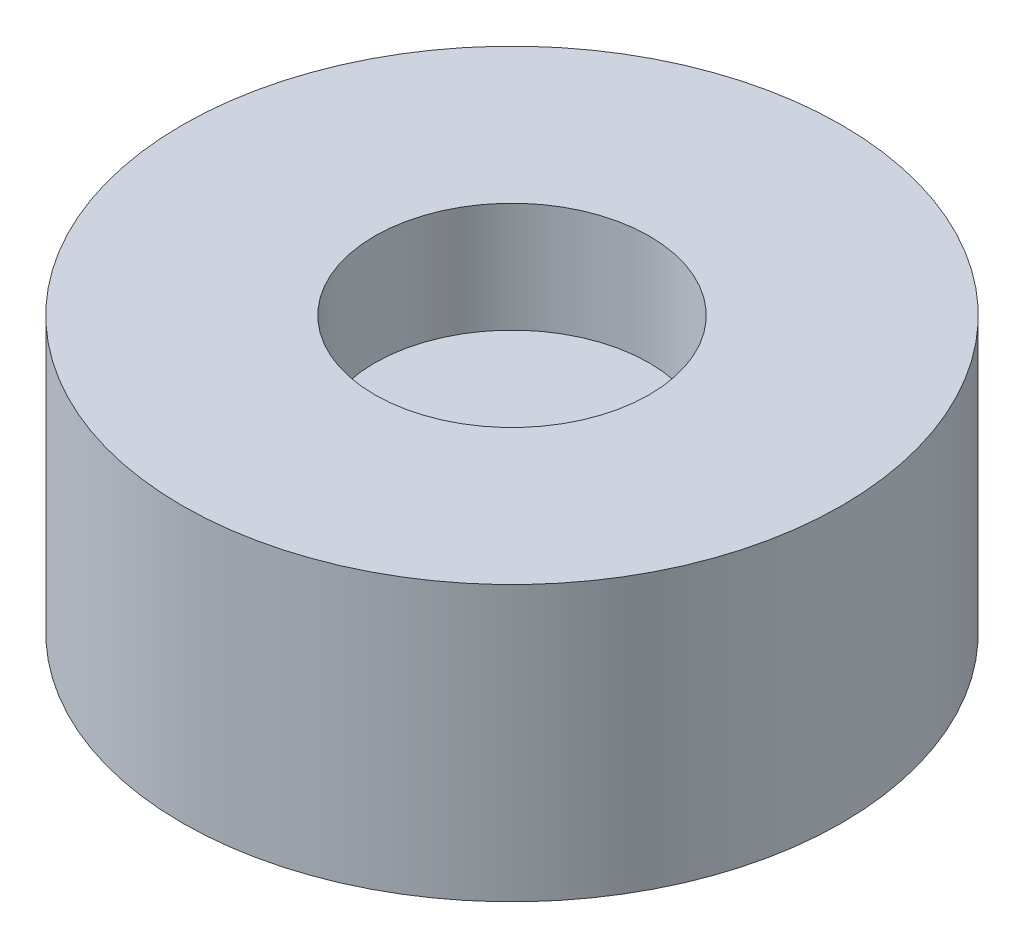
from build123d import *

# Parameters (mm, degrees)
SKETCH1_R           = 6
BOSS_EXTRUDE1_DEPTH = 5
SKETCH2_R           = 2.5
CUT_EXTRUDE1_DEPTH  = 2
SKETCH3_R           = 1
CUT_EXTRUDE2_DEPTH  = 2
FILLET1_R           = 1


with BuildPart() as part:
    # Sketch1 → Boss-Extrude1 (new body)
    with BuildSketch(Plane(origin=(0, 0, 0), x_dir=(1, 0, 0), z_dir=(0, 1, 0))):
        Circle(SKETCH1_R)
    extrude(amount=BOSS_EXTRUDE1_DEPTH)

    # Sketch2 → Cut-Extrude1 (cut)
    with BuildSketch(Plane(origin=(0, 5, 0), x_dir=(1, 0, 0), z_dir=(0, 1, 0))):
        Circle(SKETCH2_R)
    extrude(amount=-CUT_EXTRUDE1_DEPTH, mode=Mode.SUBTRACT)

    # Sketch3 → Cut-Extrude2 (cut)
    with BuildSketch(Plane.XZ):
        Circle(SKETCH3_R)
    extrude(amount=-CUT_EXTRUDE2_DEPTH, mode=Mode.SUBTRACT)

    # Fillet1
    fillet1_edges = [part.edges().sort_by_distance(p)[0] for p in [
        (-1, 2, 0),
    ]]
    fillet(fillet1_edges, radius=FILLET1_R)


solid = part.part
